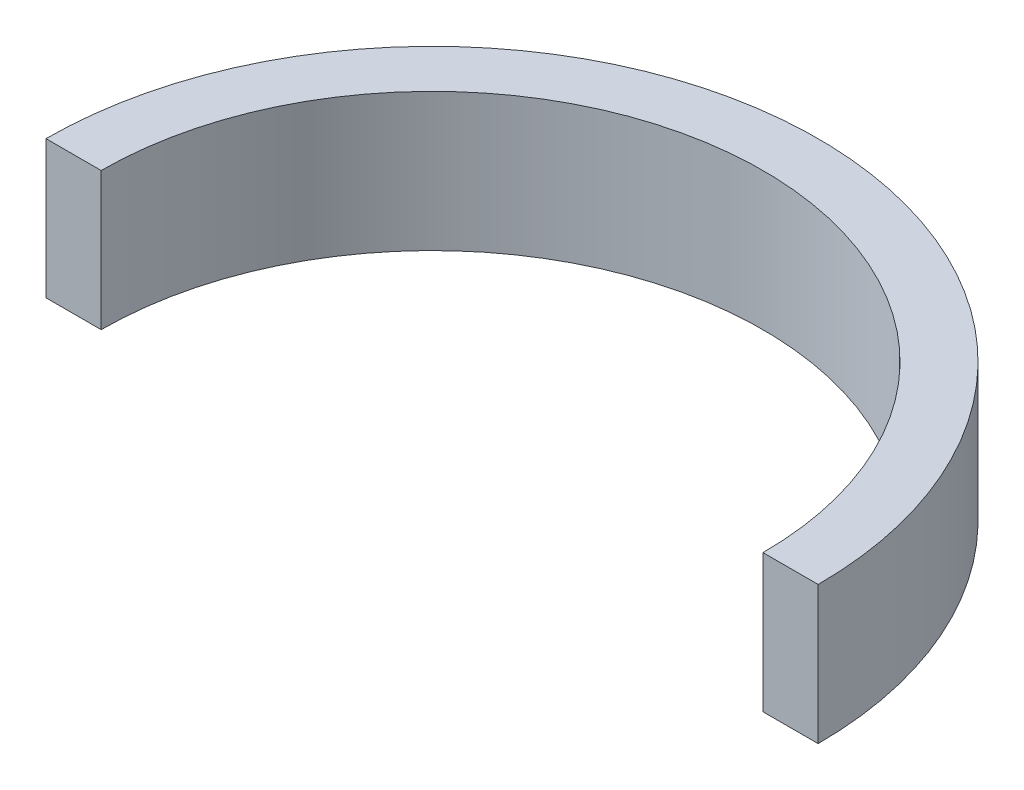
from build123d import *

# Parameters (mm, degrees)
EXTRUDE_1_DEPTH = 20


with BuildPart() as part:
    # 草图1 → 凸台-拉伸1 (new body)
    with BuildSketch(Plane(origin=(0, 0, 0), x_dir=(1, 0, 0), z_dir=(0, 1, 0))):
        with BuildLine():
            Line((-56, 0), (-48, 0))
            ThreePointArc((-48, 0), (0, 48), (48, 0))
            Line((48, 0), (56, 0))
            ThreePointArc((56, 0), (0, 56), (-56, 0))
        make_face()
    extrude(amount=EXTRUDE_1_DEPTH)


solid = part.part
